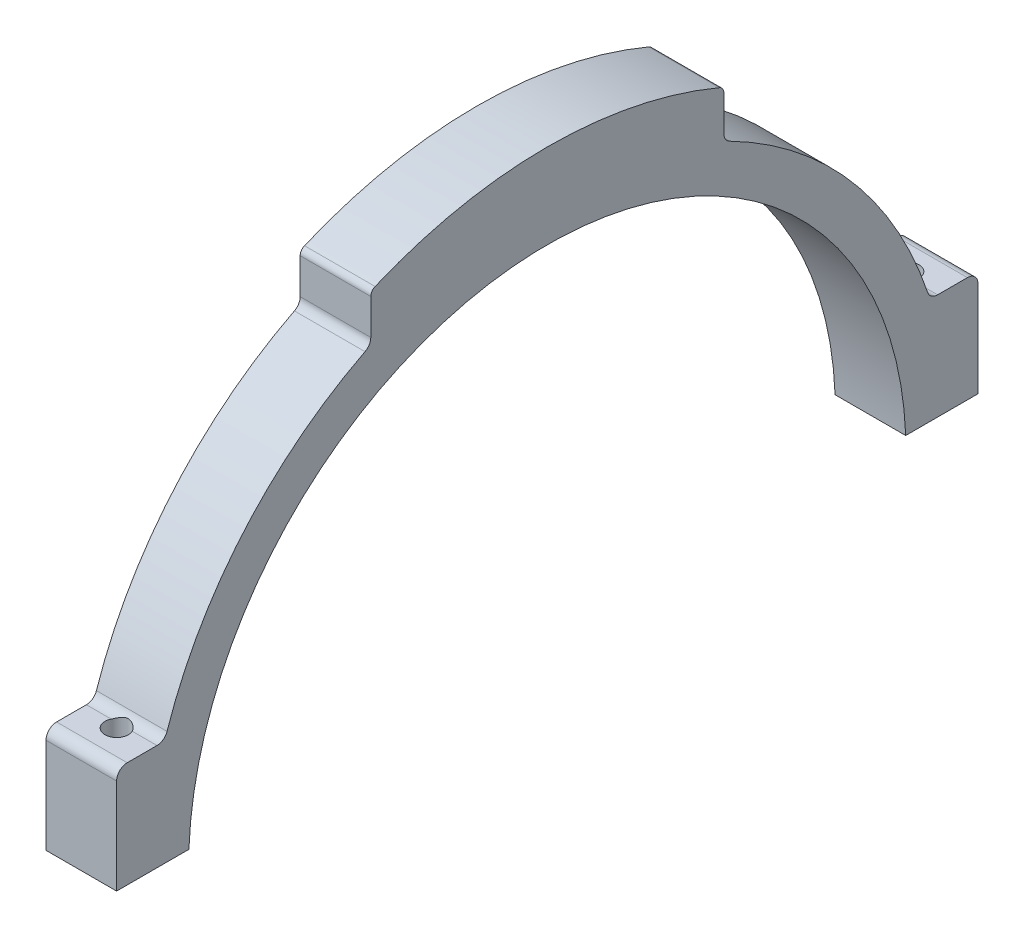
from build123d import *

# Parameters (mm, degrees)
BOSS_EXTRUDE1_DEPTH = 10
M4_TAPPED_HOLE1_D   = 3.3
FILLET1_R           = 1


with BuildPart() as part:
    # Sketch1 → Boss-Extrude1 (new body)
    with BuildSketch(Plane(origin=(0, 0, 0), x_dir=(0, 0, -1), z_dir=(1, 0, 0))):
        with BuildLine():
            ThreePointArc((25, 57.609374237), (12.766583292, 61.488652214), (0, 62.8))
            ThreePointArc((0, 62.8), (-12.766583292, 61.488652214), (-25, 57.609374237))
            Line((-25, 57.609374237), (-25, 51.929182547))
            ThreePointArc((-25, 51.929182547), (-25.220795702, 51.145833095), (-25.818181818, 50.593097233))
            ThreePointArc((-25.818181818, 50.593097233), (-43.035646203, 37.069841595), (-53.859344034, 18.039153533))
            ThreePointArc((-53.859344034, 18.039153533), (-54.405495004, 17.298046479), (-55.281685866, 17.01553963))
            Line((-55.281685866, 17.01553963), (-59.5, 17.01553963))
            ThreePointArc((-59.5, 17.01553963), (-60.560660172, 16.576199802), (-61, 15.51553963))
            Line((-61, 15.51553963), (-61, 2.01553963))
            Line((-61, 2.01553963), (-50.76, 2.01553963))
            ThreePointArc((-50.76, 2.01553963), (0, 50.8), (50.76, 2.01553963))
            Line((50.76, 2.01553963), (61, 2.01553963))
            Line((61, 2.01553963), (61, 15.51553963))
            ThreePointArc((61, 15.51553963), (60.560660172, 16.576199802), (59.5, 17.01553963))
            Line((59.5, 17.01553963), (55.281685866, 17.01553963))
            ThreePointArc((55.281685866, 17.01553963), (54.405495004, 17.298046479), (53.859344034, 18.039153533))
            ThreePointArc((53.859344034, 18.039153533), (43.035646203, 37.069841595), (25.818181818, 50.593097233))
            ThreePointArc((25.818181818, 50.593097233), (25.220795702, 51.145833095), (25, 51.929182547))
            Line((25, 51.929182547), (25, 57.609374237))
        make_face()
    extrude(amount=BOSS_EXTRUDE1_DEPTH)

    # M4 Tapped Hole1 (through all)
    with Locations(Plane.XZ.offset(-2.01553963)):
        with Locations((5, -56), (5, 56)):
            Hole(M4_TAPPED_HOLE1_D / 2)

    # Fillet1
    fillet1_edges = [part.edges().sort_by_distance(p)[0] for p in [
        (5, 57.609374237, -25),
        (5, 57.609374237, 25),
    ]]
    fillet(fillet1_edges, radius=FILLET1_R)


solid = part.part
